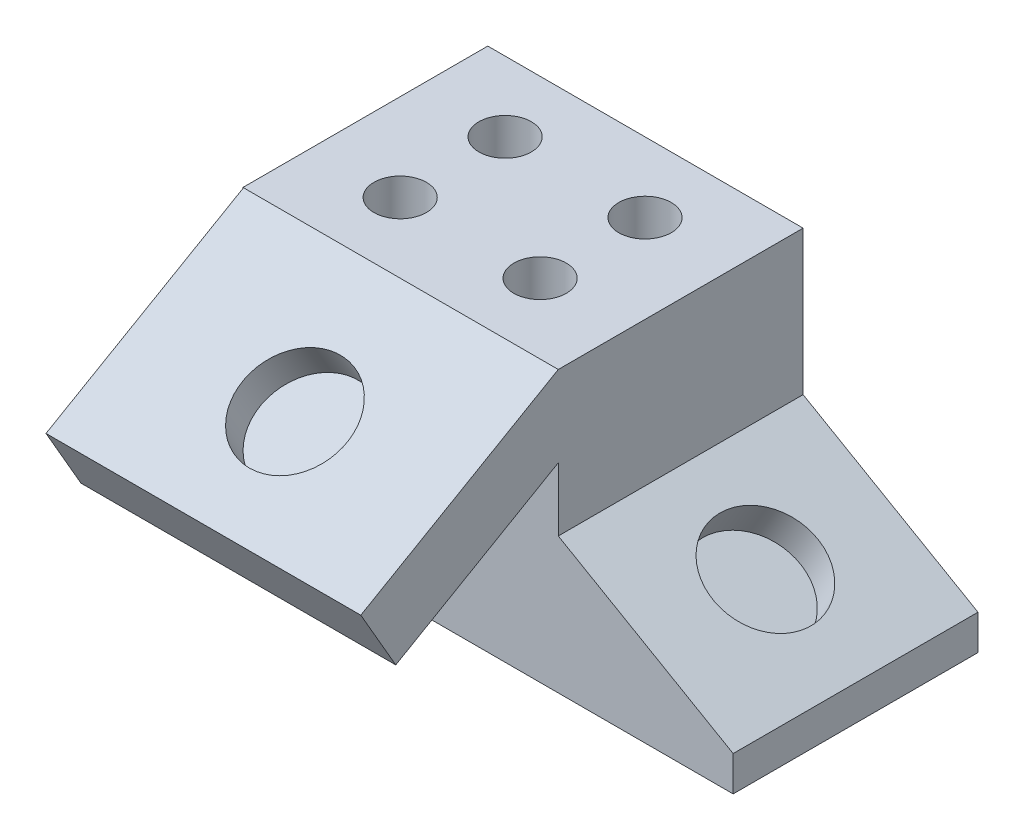
from build123d import *

# Parameters (mm, degrees)
BOSS_EXTRUDE1_DEPTH = 44.45
BOSS_EXTRUDE2_DEPTH = 57.15
SKETCH5_R           = 9.525
CUT_EXTRUDE1_DEPTH  = 6.35
SKETCH6_R           = 9.525
CUT_EXTRUDE2_DEPTH  = 6.35
SKETCH7_R           = 4.7625
CUT_EXTRUDE3_DEPTH  = 12.7


with BuildPart() as part:
    # Sketch1 → Boss-Extrude1 (new body)
    with BuildSketch(Plane.XY):
        Polygon((0, 0), (0, 50.862487244), (57.248927697, 50.862487244), (57.248927697, 24.680871047), (88.998927697, 6.35), (88.998927697, 0), align=None)
    extrude(amount=BOSS_EXTRUDE1_DEPTH)

    # Sketch2 → Boss-Extrude2 (add)
    with BuildSketch(Plane(origin=(57.248927697, 0, 0), x_dir=(0, 0, -1), z_dir=(1, 0, 0))):
        Polygon((-44.45, 50.862487244), (-80.305183767, 30.161487244), (-73.955183767, 19.162964616), (-44.45, 36.197790407), align=None)
    extrude(amount=-BOSS_EXTRUDE2_DEPTH)

    # Sketch5 → Cut-Extrude1 (cut)
    with BuildSketch(Plane(origin=(0, 57.394280032, 33.136603026), x_dir=(1, 0, 0), z_dir=(0, 0.866025404, 0.5))):
        with Locations((28.800927697, -35.415585576)):
            Circle(SKETCH5_R)
    extrude(amount=-CUT_EXTRUDE1_DEPTH, mode=Mode.SUBTRACT)

    # Sketch6 → Cut-Extrude2 (cut)
    with BuildSketch(Plane(origin=(24.999362581, 43.300166148, 0), x_dir=(0.866025404, -0.5, 0), z_dir=(0.5, 0.866025404, 0))):
        with Locations((54.850332296, -22.098)):
            Circle(SKETCH6_R)
    extrude(amount=-CUT_EXTRUDE2_DEPTH, mode=Mode.SUBTRACT)

    # Sketch7 → Cut-Extrude3 (cut)
    with BuildSketch(Plane(origin=(0, 50.862487244, 0), x_dir=(1, 0, 0), z_dir=(0, 1, 0))):
        with Locations((15.846927697, -12.7)):
            Circle(SKETCH7_R)
        with Locations((15.846927697, -31.75)):
            Circle(SKETCH7_R)
        with Locations((41.246927697, -31.75)):
            Circle(SKETCH7_R)
        with Locations((41.246927697, -12.7)):
            Circle(SKETCH7_R)
    extrude(amount=-CUT_EXTRUDE3_DEPTH, mode=Mode.SUBTRACT)


solid = part.part
